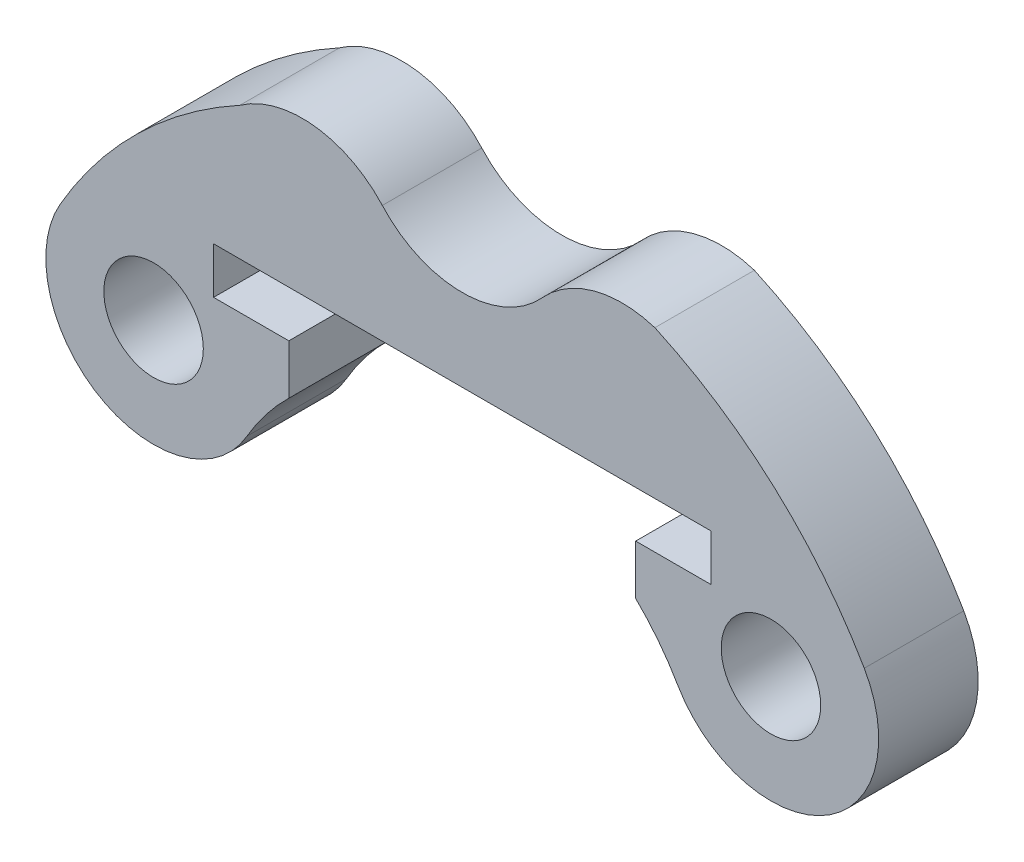
from build123d import *

# Parameters (mm, degrees)
ESQUISSE1_R        = 1.5
BOSS_EXTRU_2_DEPTH = 3


with BuildPart() as part:
    # Esquisse1 → Boss.-Extru.2 (new body)
    with BuildSketch(Plane.XY):
        with BuildLine():
            Line((-5.230618988, 6.875), (-7.5, 6.875))
            Line((-7.5, 6.875), (-7.5, 8.275))
            Line((-7.5, 8.275), (7.5, 8.275))
            Line((7.5, 8.275), (7.5, 6.875))
            Line((7.5, 6.875), (5.230618988, 6.875))
            Line((5.230618988, 6.875), (5.230618988, 5.375))
            ThreePointArc((5.230618988, 5.375), (5.918936429, 4.606103727), (6.495190528, 3.75))
            ThreePointArc((6.495190528, 3.75), (10.934773091, 2.560417438), (12.124355653, 7))
            ThreePointArc((12.124355653, 7), (9.414650572, 10.36167721), (5.80943088, 12.737759334))
            ThreePointArc((5.80943088, 12.737759334), (3.975330286, 12.779130538), (2.411034891, 11.820685714))
            ThreePointArc((2.411034891, 11.820685714), (0, 10.75), (-2.411034891, 11.820685714))
            ThreePointArc((-2.411034891, 11.820685714), (-4.47014813, 12.872261577), (-6.707371512, 12.288660114))
            ThreePointArc((-6.707371512, 12.288660114), (-9.780131311, 10.017436376), (-12.124355653, 7))
            ThreePointArc((-12.124355653, 7), (-10.934773091, 2.560417438), (-6.495190528, 3.75))
            ThreePointArc((-6.495190528, 3.75), (-5.918936429, 4.606103727), (-5.230618988, 5.375))
            Line((-5.230618988, 5.375), (-5.230618988, 6.875))
        make_face()
        with Locations((9.309773091, 5.375)):
            Circle(ESQUISSE1_R, mode=Mode.SUBTRACT)
        with Locations((-9.309773091, 5.375)):
            Circle(ESQUISSE1_R, mode=Mode.SUBTRACT)
    extrude(amount=BOSS_EXTRU_2_DEPTH)


solid = part.part
